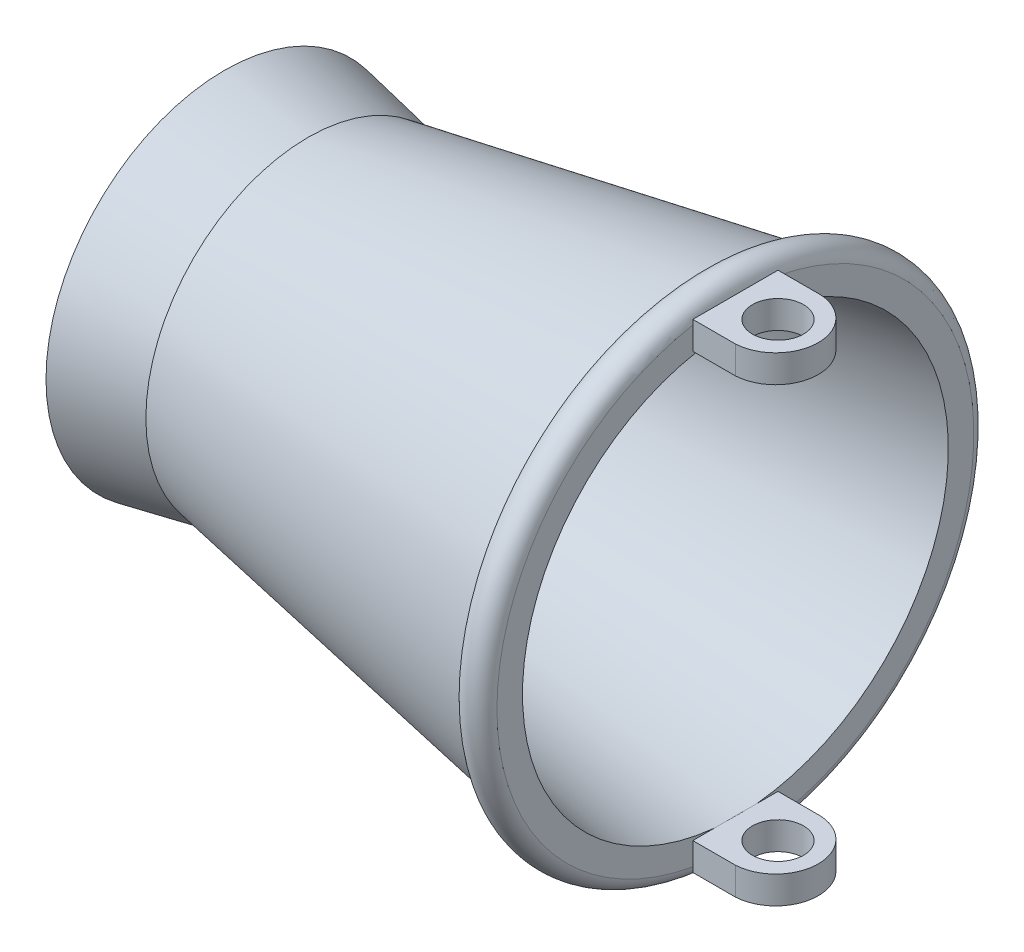
from build123d import *

# Parameters (mm, degrees)
SKETCH2_W           = 5
SKETCH2_H           = 1.623250271
BOSS_EXTRUDE1_DEPTH = 5
CUT_EXTRUDE1_DEPTH  = 26.500274
SKETCH4_R           = 1.5
CUT_EXTRUDE2_DEPTH  = 26.500274


with BuildPart() as part:
    # Sketch1 → Revolve1 (revolve)
    with BuildSketch(Plane(origin=(0, 0, 0), x_dir=(1, 0, 0), z_dir=(0, 1, 0))):
        with BuildLine():
            Line((1.257722515, 9.518975428), (24.380809012, 13.648394277))
            ThreePointArc((24.380809012, 13.648394277), (25.189431543, 14.808622531), (26.349659797, 14))
            Line((26.349659797, 14), (26.349659797, 12.5))
            Line((26.349659797, 12.5), (2.479732811, 8.649095646))
            Line((2.479732811, 8.649095646), (2.479732811, 0))
            Line((2.479732811, 0), (0.979732811, 0))
            Line((0.979732811, 0), (0.979732811, 8.0625))
            Line((0.979732811, 8.0625), (-3.931590203, 9))
            Line((-3.931590203, 9), (-3.650340203, 10.473396904))
            Line((-3.650340203, 10.473396904), (1.257722515, 9.518975428))
        make_face()
    revolve(axis=Axis((-20.81402906, 0, 0), (1, 0, 0)))

    # Sketch2 → Boss-Extrude1 (add)
    with BuildSketch(Plane(origin=(26.349659797, 0, 0), x_dir=(0, 0, -1), z_dir=(1, 0, 0))):
        with Locations((0, 13.250136984)):
            Rectangle(SKETCH2_W, SKETCH2_H)
        with Locations((0, -13.250136984)):
            Rectangle(SKETCH2_W, SKETCH2_H)
    extrude(amount=BOSS_EXTRUDE1_DEPTH)

    # Sketch3 → Cut-Extrude1 (cut)
    with BuildSketch(Plane(origin=(0, 14.061762119, 0), x_dir=(1, 0, 0), z_dir=(0, 1, 0))):
        with BuildLine():
            Line((28.849659797, 2.5), (31.349659797, 2.5))
            Line((31.349659797, 2.5), (31.349659797, -2.5))
            Line((31.349659797, -2.5), (28.849659797, -2.5))
            ThreePointArc((28.849659797, -2.5), (31.217194374, 0), (28.849659797, 2.5))
        make_face()
    cut_extrude1 = extrude(amount=-CUT_EXTRUDE1_DEPTH, mode=Mode.SUBTRACT)

    # Mirror1: Cut-Extrude1 across plane
    add(cut_extrude1.mirror(Plane.ZX), mode=Mode.SUBTRACT)

    # Sketch4 → Cut-Extrude2 (cut)
    with BuildSketch(Plane(origin=(0, 14.061762119, 0), x_dir=(1, 0, 0), z_dir=(0, 1, 0))):
        with Locations((28.849659797, 0)):
            Circle(SKETCH4_R)
    cut_extrude2 = extrude(amount=-CUT_EXTRUDE2_DEPTH, mode=Mode.SUBTRACT)

    # Mirror2: Cut-Extrude2 across plane
    add(cut_extrude2.mirror(Plane.ZX), mode=Mode.SUBTRACT)


solid = part.part
